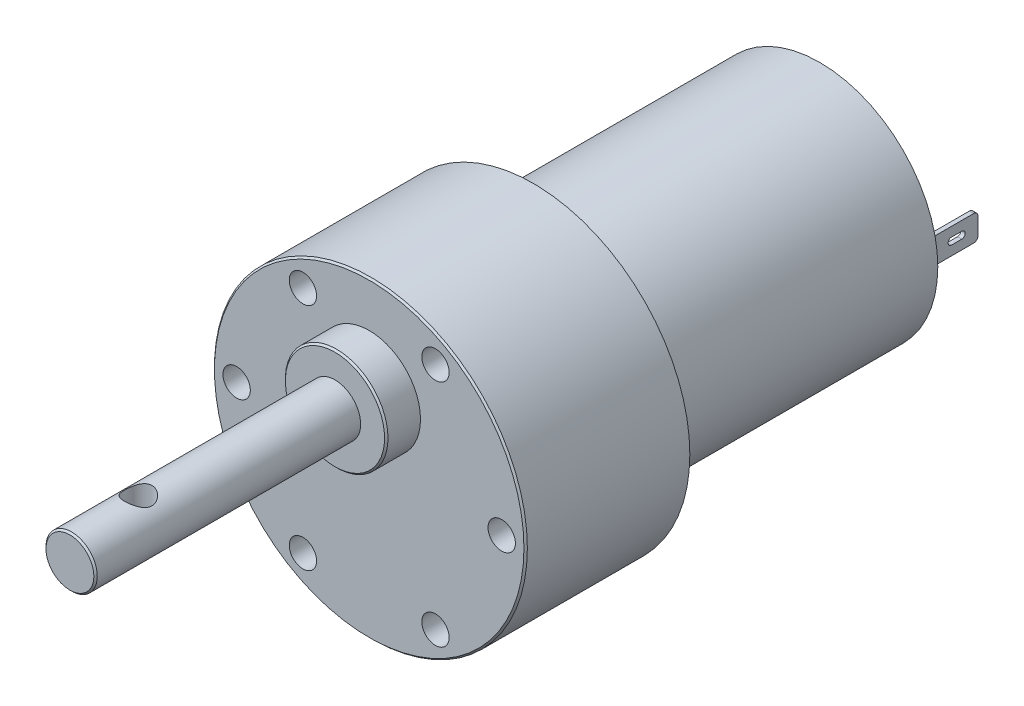
from build123d import *

# Parameters (mm, degrees)
SKETCH1_R               = 18.3
BOSS_EXTRUDE1_DEPTH     = 19.2
SKETCH2_R               = 1.6
CUT_EXTRUDE1_DEPTH      = 3.5
SKETCH3_R               = 3
BOSS_EXTRUDE2_DEPTH     = 35
SKETCH3_3_R             = 6
SKETCH3_3_R_2           = 3
BOSS_EXTRUDE3_DEPTH     = 4
SKETCH4_R               = 13.8
BOSS_EXTRUDE4_DEPTH     = 33.5
SKETCH5_R               = 5
BOSS_EXTRUDE5_DEPTH     = 3
SKETCH6_R               = 1
BOSS_EXTRUDE6_DEPTH     = 5
SKETCH7_W               = 0.5
SKETCH7_H               = 3
BOSS_EXTRUDE7_DEPTH     = 6.5
CUT_EXTRUDE2_DEPTH      = 0.5
FILLET1_R               = 0.5
CHAMFER1_SIZE           = 0.2
CUT_EXTRUDE3_DEPTH      = 63.550939242
CUT_EXTRUDE3_DEPTH_BACK = 63.550939242
SKETCH9_R               = 1.6


with BuildPart() as part:
    # Sketch1 → Boss-Extrude1 (new body)
    with BuildSketch(Plane.XY):
        Circle(SKETCH1_R)
    extrude(amount=BOSS_EXTRUDE1_DEPTH)

    # Sketch2 → Cut-Extrude1 (cut)
    with BuildSketch(Plane.XY.offset(19.2)):
        with Locations((-7.75, 13.423393759)):
            Circle(SKETCH2_R)
        with Locations((7.75, 13.423393759)):
            Circle(SKETCH2_R)
        with Locations((-15.5, 0)):
            Circle(SKETCH2_R)
        with Locations((-7.75, -13.423393759)):
            Circle(SKETCH2_R)
        with Locations((7.75, -13.423393759)):
            Circle(SKETCH2_R)
        with Locations((15.5, 0)):
            Circle(SKETCH2_R)
    extrude(amount=-CUT_EXTRUDE1_DEPTH, mode=Mode.SUBTRACT)

    # Sketch3 → Boss-Extrude2 (add)
    with BuildSketch(Plane.XY.offset(19.2)):
        with Locations((0, 7)):
            Circle(SKETCH3_R)
    extrude(amount=BOSS_EXTRUDE2_DEPTH)

    # Sketch3_3 → Boss-Extrude3 (add)
    with BuildSketch(Plane.XY.offset(19.2)):
        with Locations((0, 7)):
            Circle(SKETCH3_3_R)
        with Locations((0, 7)):
            Circle(SKETCH3_3_R_2, mode=Mode.SUBTRACT)
    extrude(amount=BOSS_EXTRUDE3_DEPTH)

    # Sketch4 → Boss-Extrude4 (add)
    with BuildSketch(Plane(origin=(0, 0, 0), x_dir=(-1, 0, 0), z_dir=(0, 0, -1))):
        Circle(SKETCH4_R)
    extrude(amount=BOSS_EXTRUDE4_DEPTH)

    # Sketch5 → Boss-Extrude5 (add)
    with BuildSketch(Plane(origin=(0, 0, -33.5), x_dir=(-1, 0, 0), z_dir=(0, 0, -1))):
        Circle(SKETCH5_R)
    extrude(amount=BOSS_EXTRUDE5_DEPTH)

    # Sketch6 → Boss-Extrude6 (add)
    with BuildSketch(Plane(origin=(0, 0, -36.5), x_dir=(-1, 0, 0), z_dir=(0, 0, -1))):
        Circle(SKETCH6_R)
    extrude(amount=BOSS_EXTRUDE6_DEPTH)

    # Sketch7 → Boss-Extrude7 (add)
    with BuildSketch(Plane(origin=(0, 0, -33.5), x_dir=(-1, 0, 0), z_dir=(0, 0, -1))):
        with Locations((-11.75, 0)):
            Rectangle(SKETCH7_W, SKETCH7_H)
        with Locations((11.75, 0)):
            Rectangle(SKETCH7_W, SKETCH7_H)
    extrude(amount=BOSS_EXTRUDE7_DEPTH)

    # Sketch8 → Cut-Extrude2 (cut)
    with BuildSketch(Plane(origin=(12, 0, 0), x_dir=(0, 0, -1), z_dir=(1, 0, 0))):
        with BuildLine():
            Line((38.1, -0.4), (36.9, -0.4))
            ThreePointArc((36.9, -0.4), (36.5, 0), (36.9, 0.4))
            Line((36.9, 0.4), (38.1, 0.4))
            ThreePointArc((38.1, 0.4), (38.5, 0), (38.1, -0.4))
        make_face()
    cut_extrude2 = extrude(amount=-CUT_EXTRUDE2_DEPTH, mode=Mode.SUBTRACT)

    # Mirror2: Cut-Extrude2 across plane
    add(cut_extrude2.mirror(Plane(origin=(0, 0, 0), x_dir=(0, 0, 1), z_dir=(1, 0, 0))), mode=Mode.SUBTRACT)

    # Fillet1
    fillet1_edges = [part.edges().sort_by_distance(p)[0] for p in [
        (-11.75, 1.5, -40),
        (-11.75, -1.5, -40),
        (11.75, 1.5, -40),
        (11.75, -1.5, -40),
    ]]
    fillet(fillet1_edges, radius=FILLET1_R)

    # Chamfer1
    chamfer1_edges = [part.edges().sort_by_distance(p)[0] for p in [
        (-18.3, 0, 19.2),
        (-6, 7, 23.2),
        (-3, 7, 54.2),
    ]]
    chamfer(chamfer1_edges, length=CHAMFER1_SIZE)

    # Sketch9 → Cut-Extrude3 (cut, two sides: drawn at the far end of the back side and taken through both)
    with BuildSketch(Plane(origin=(0, 7, 0), x_dir=(1, 0, 0), z_dir=(0, 1, 0)).offset(-CUT_EXTRUDE3_DEPTH_BACK)):
        with Locations((0, -46.2)):
            Circle(SKETCH9_R)
    extrude(amount=CUT_EXTRUDE3_DEPTH + CUT_EXTRUDE3_DEPTH_BACK, mode=Mode.SUBTRACT)


solid = part.part
